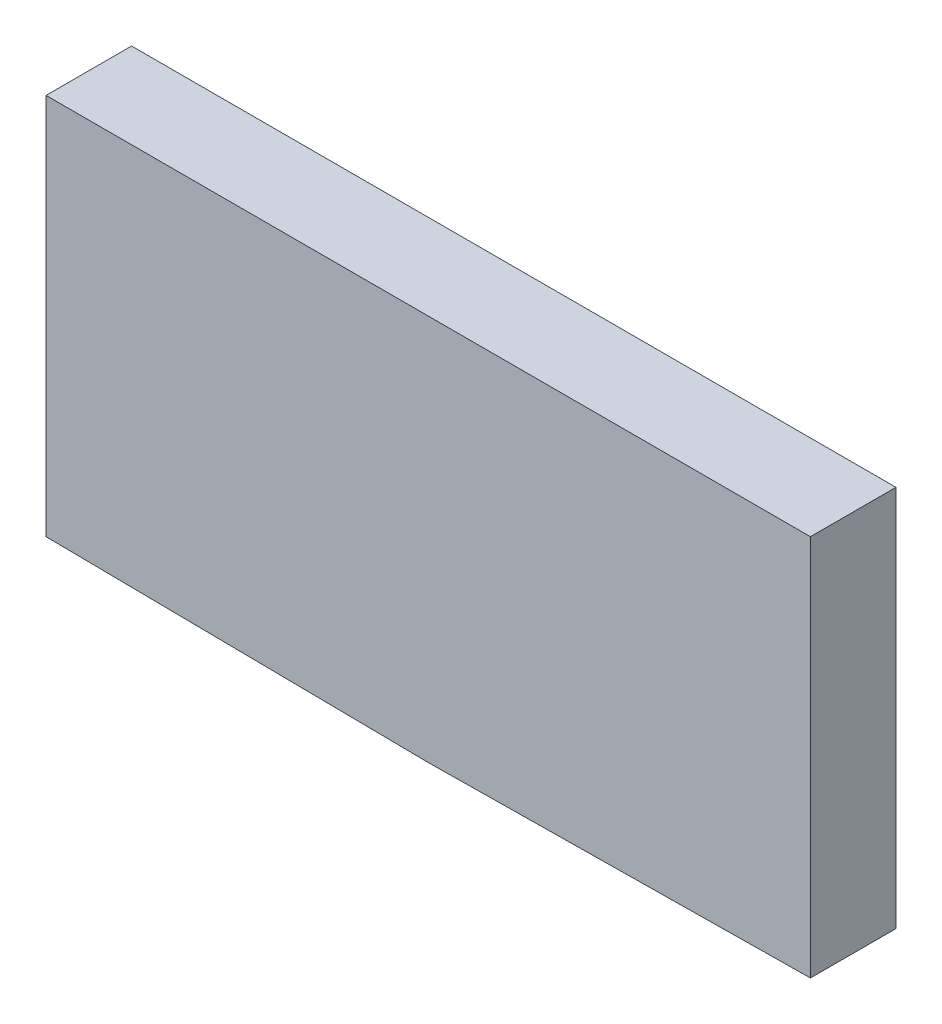
from build123d import *

# Parameters (mm, degrees)
EXTRUDE_1_DEPTH = 3.2


with BuildPart() as part:
    # 草图1 → 凸台-拉伸1 (new body)
    with BuildSketch(Plane.XY):
        Polygon((14.3, 14.468160442), (-14.3, 14.468160442), (-14.3, 0.168160442), (0, 0), (14.3, 0.168160442), align=None)
    extrude(amount=EXTRUDE_1_DEPTH)


solid = part.part
